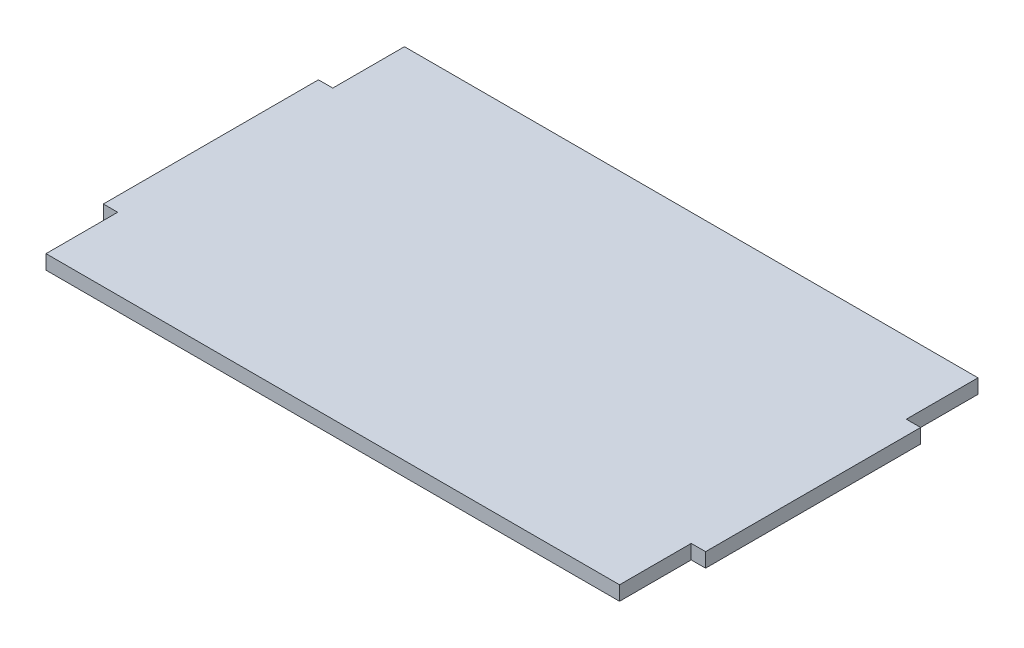
from build123d import *

# Parameters (mm, degrees)
BOSS_EXTRUDE1_DEPTH = 4


with BuildPart() as part:
    # Sketch2 → Boss-Extrude1 (new body)
    with BuildSketch(Plane(origin=(0, 0, 0), x_dir=(1, 0, 0), z_dir=(0, 1, 0))):
        Polygon((0, 0), (160, 0), (160, -20), (164, -20), (164, -80), (160, -80), (160, -100), (0, -100), (0, -80), (-4, -80), (-4, -20), (0, -20), align=None)
    extrude(amount=BOSS_EXTRUDE1_DEPTH)


solid = part.part
